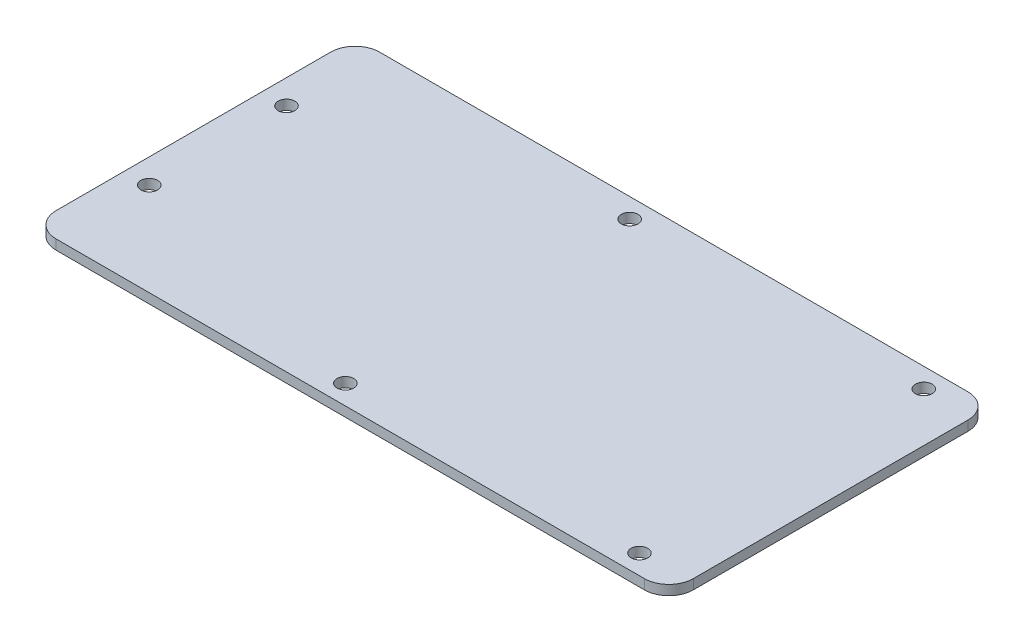
from build123d import *

# Parameters (mm, degrees)
SKETCH1_W            = 130
SKETCH1_H            = 66
BOSS_EXTRUDE1_DEPTH  = 2
FILLET1_R            = 5
M3_CLEARANCE_HOLE1_D = 3.4


with BuildPart() as part:
    # Sketch1 → Boss-Extrude1 (new body)
    with BuildSketch(Plane(origin=(0, 0, 0), x_dir=(1, 0, 0), z_dir=(0, 1, 0))):
        with Locations((65, 33)):
            Rectangle(SKETCH1_W, SKETCH1_H)
    extrude(amount=BOSS_EXTRUDE1_DEPTH)

    # Fillet1
    fillet1_edges = [part.edges().sort_by_distance(p)[0] for p in [
        (0, 1, -66),
        (130, 1, -66),
        (130, 1, 0),
        (0, 1, 0),
    ]]
    fillet(fillet1_edges, radius=FILLET1_R)

    # M3 Clearance Hole1 (through all)
    with Locations(Plane(origin=(0, 2, 0), x_dir=(1, 0, 0), z_dir=(0, 1, 0))):
        with Locations((5, 19), (60, 4), (120, 4), (120, 62), (60, 62), (5, 47)):
            Hole(M3_CLEARANCE_HOLE1_D / 2)


solid = part.part
